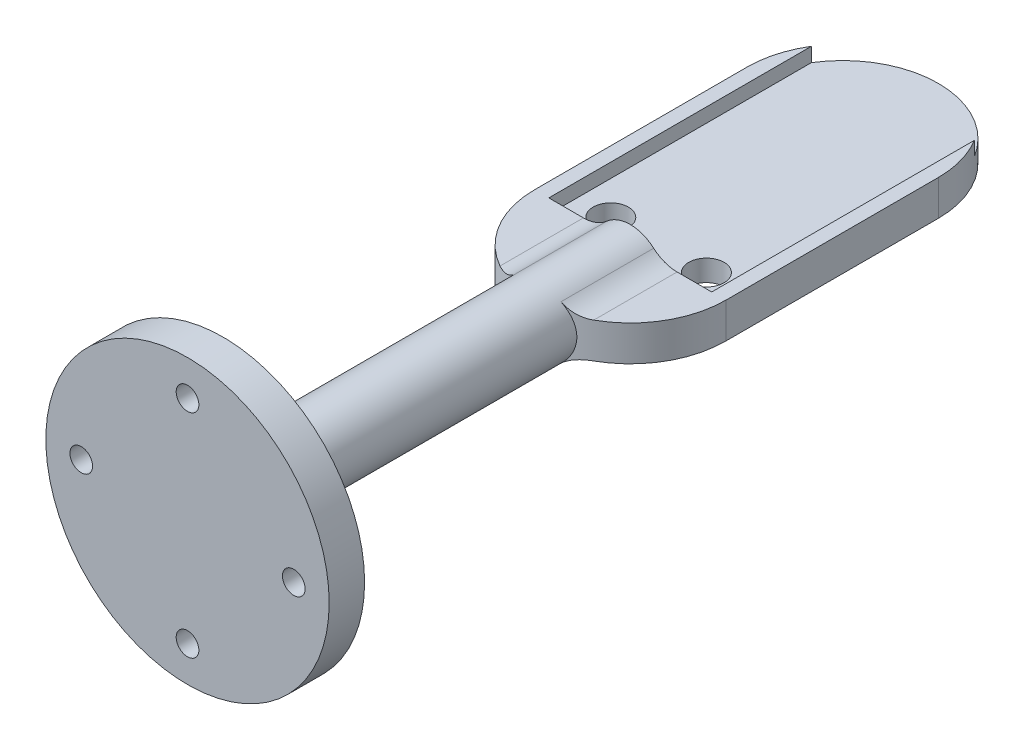
from build123d import *

# Parameters (mm, degrees)
SKETCH_1_R          = 20
SKETCH_1_R_2        = 1.6
EXTRUDE_1_DEPTH     = 2.5
SWEEP_1_PROFILE_R   = 5
EXTRUDE_2_DEPTH     = 2.5
SKETCH_10_W         = 23
SKETCH_10_H         = 44.650800955
CUT_EXTRUDE_1_DEPTH = 2
SKETCH_11_R         = 2.5
CUT_EXTRUDE_2_DEPTH = 21.5
FILLET_1_R          = 5


with BuildPart() as part:
    # 草图1 → 凸台-拉伸1 (new body, symmetric)
    with BuildSketch(Plane.XY):
        Circle(SKETCH_1_R)
        with Locations((0, 15)):
            Circle(SKETCH_1_R_2, mode=Mode.SUBTRACT)
        with Locations((15, 0)):
            Circle(SKETCH_1_R_2, mode=Mode.SUBTRACT)
        with Locations((0, -15)):
            Circle(SKETCH_1_R_2, mode=Mode.SUBTRACT)
        with Locations((-15, 0)):
            Circle(SKETCH_1_R_2, mode=Mode.SUBTRACT)
    extrude(amount=EXTRUDE_1_DEPTH, both=True)

    # 扫描1: sweep along a path in 草图4
    with BuildLine(Plane(origin=(0, 0, 0), x_dir=(1, 0, 0), z_dir=(0, 1, 0))) as sweep_1_path:
        Line((0, 0), (0, 60))
    # 扫描1 profile (on start of the path) → 扫描1 (sweep)
    with BuildSketch(Plane(origin=(0, 0, 0), x_dir=(-1, 0, 0), z_dir=(0, 0, -1))):
        Circle(SWEEP_1_PROFILE_R)
    sweep(path=sweep_1_path.line)

    # 草图9 → 凸台-拉伸2 (add, symmetric)
    with BuildSketch(Plane(origin=(0, 0, 0), x_dir=(1, 0, 0), z_dir=(0, 1, 0))):
        with BuildLine():
            Line((13.5, 90), (13.5, 60))
            ThreePointArc((13.5, 60), (0, 46.5), (-13.5, 60))
            Line((-13.5, 60), (-13.5, 90))
            ThreePointArc((-13.5, 90), (0, 103.5), (13.5, 90))
        make_face()
    extrude(amount=EXTRUDE_2_DEPTH, both=True)

    # 草图10 → 切除-拉伸1 (cut)
    with BuildSketch(Plane(origin=(0, 2.5, 0), x_dir=(1, 0, 0), z_dir=(0, 1, 0))):
        with Locations((0, 82.325400478)):
            Rectangle(SKETCH_10_W, SKETCH_10_H)
    extrude(amount=-CUT_EXTRUDE_1_DEPTH, mode=Mode.SUBTRACT)

    # 草图11 → 切除-拉伸2 (cut, through all)
    with BuildSketch(Plane(origin=(0, 0.5, 0), x_dir=(1, 0, 0), z_dir=(0, 1, 0))):
        with Locations((-6.75, 64)):
            Circle(SKETCH_11_R)
        with Locations((6.75, 64)):
            Circle(SKETCH_11_R)
    extrude(amount=-CUT_EXTRUDE_2_DEPTH, mode=Mode.SUBTRACT)

    # 圆角1
    fillet_1_edges = [part.edges().sort_by_distance(p)[0] for p in [
        (5, 0, -2.5),
        (4.330127019, -2.5, -53.606644074),
        (-4.330127019, -2.5, -53.606644074),
        (4.330127019, 2.5, -53.606644074),
        (-4.330127019, 2.5, -53.606644074),
    ]]
    fillet(fillet_1_edges, radius=FILLET_1_R)


solid = part.part
